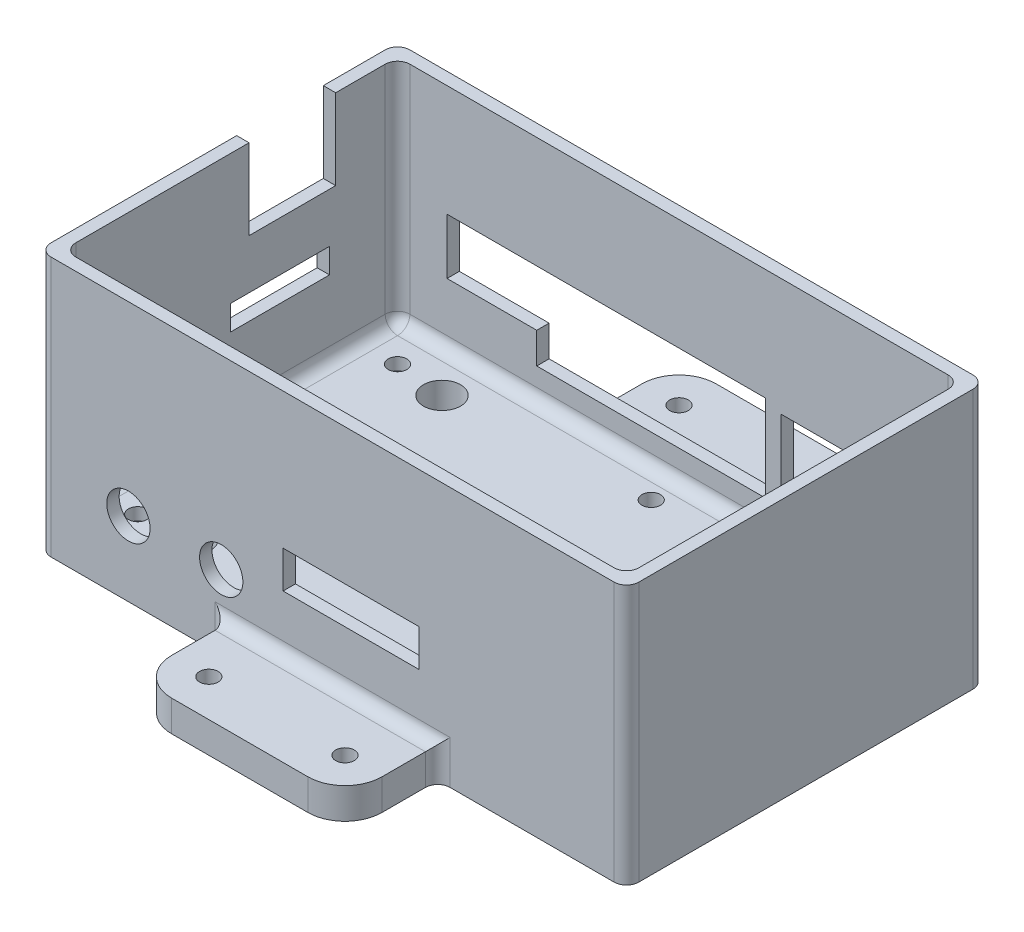
from build123d import *

# Parameters (mm, degrees)
SKETCH1_W                                          = 93
SKETCH1_H                                          = 58
BOSS_EXTRUDE1_DEPTH                                = 42
SKETCH2_W                                          = 91
SKETCH2_H                                          = 54
CUT_EXTRUDE1_DEPTH                                 = 19
CUT_EXTRUDE2_DEPTH                                 = 18
SKETCH4_W                                          = 58
SKETCH4_H                                          = 42
BOSS_EXTRUDE2_DEPTH                                = 2
SKETCH5_W                                          = 34
SKETCH5_H                                          = 5
BOSS_EXTRUDE3_DEPTH                                = 15
CUT_EXTRUDE3_REACH                                 = 97
SKETCH6_W                                          = 13.999999973
SKETCH6_H                                          = 12.999999419
CUT_EXTRUDE4_DEPTH                                 = 18
CUT_EXTRUDE5_REACH                                 = 97
SKETCH8_W                                          = 16
SKETCH8_H                                          = 4
SKETCH9_W                                          = 22.000000328
SKETCH9_H                                          = 6
CUT_EXTRUDE6_DEPTH                                 = 74
SKETCH10_W                                         = 34
SKETCH10_H                                         = 5
BOSS_EXTRUDE4_DEPTH                                = 15
F_3_0_3_DIAMETER_HOLE1_D                           = 3
F_3_0_3_DIAMETER_HOLE1_DEPTH                       = 5
F_6_0_6_DIAMETER_HOLE1_D                           = 6
F_6_0_6_DIAMETER_HOLE1_DEPTH                       = 5
F_7_0_7_DIAMETER_HOLE1_D                           = 7
F_7_0_7_DIAMETER_HOLE1_DEPTH                       = 2
F_8_0_8_DIAMETER_HOLE1_D                           = 8
F_8_0_8_DIAMETER_HOLE1_DEPTH                       = 2
CBORE_FOR_M2_5_HEX_HEAD_MACHINE_SCREW1_D           = 3
CBORE_FOR_M2_5_HEX_HEAD_MACHINE_SCREW1_DEPTH       = 42
CBORE_FOR_M2_5_HEX_HEAD_MACHINE_SCREW1_CBORE_D     = 6
CBORE_FOR_M2_5_HEX_HEAD_MACHINE_SCREW1_CBORE_DEPTH = 3
FILLET1_R                                          = 2
FILLET2_R                                          = 6


with BuildPart() as part:
    # Sketch1 → Boss-Extrude1 (new body)
    with BuildSketch(Plane.XZ):
        with Locations((-1, 0)):
            Rectangle(SKETCH1_W, SKETCH1_H)
    extrude(amount=-BOSS_EXTRUDE1_DEPTH)

    # Sketch2 → Cut-Extrude1 (cut)
    with BuildSketch(Plane(origin=(0, 42, 0), x_dir=(-1, 0, 0), z_dir=(0, 1, 0))):
        Rectangle(SKETCH2_W, SKETCH2_H)
    extrude(amount=-CUT_EXTRUDE1_DEPTH, mode=Mode.SUBTRACT)

    # Sketch3 → Cut-Extrude2 (cut)
    with BuildSketch(Plane(origin=(0, 23, 0), x_dir=(-1, 0, 0), z_dir=(0, 1, 0))):
        Polygon((-35.5, -29), (-16.5, -29), (-16.5, -27), (45.5, -27), (45.5, 27), (-45.5, 27), (-45.5, -27), (-35.5, -27), align=None)
    extrude(amount=-CUT_EXTRUDE2_DEPTH, mode=Mode.SUBTRACT)

    # Sketch4 → Boss-Extrude2 (add)
    with BuildSketch(Plane(origin=(45.5, 0, 0), x_dir=(0, 0, -1), z_dir=(1, 0, 0))):
        with Locations((0, 21)):
            Rectangle(SKETCH4_W, SKETCH4_H)
    extrude(amount=BOSS_EXTRUDE2_DEPTH)

    # Sketch5 → Boss-Extrude3 (add)
    with BuildSketch(Plane(origin=(0, 0, -29), x_dir=(-1, 0, 0), z_dir=(0, 0, -1))):
        with Locations((0, 2.5)):
            Rectangle(SKETCH5_W, SKETCH5_H)
    extrude(amount=BOSS_EXTRUDE3_DEPTH)

    # Sketch6 → Cut-Extrude3 (cut, up to next)
    with BuildSketch(Plane.ZY.offset(47.5), mode=Mode.PRIVATE) as cut_extrude3_sk1:
        with Locations((-10.000000013, 35.50000029)):
            Rectangle(SKETCH6_W, SKETCH6_H)
    cut_extrude3_tool1 = extrude(cut_extrude3_sk1.sketch, amount=-CUT_EXTRUDE3_REACH, mode=Mode.PRIVATE) & part.part
    add(cut_extrude3_tool1.solids().sort_by_distance((-47.5, 35.5, -10))[0], mode=Mode.SUBTRACT)

    # Sketch7 → Cut-Extrude4 (cut, through all)
    with BuildSketch(Plane.XY.offset(-27)):
        Polygon((14.000000071, 10), (14.000000071, 24), (-37.500000057, 24), (-37.500000057, 15), (-23.000000328, 15), (-23.000000328, 10), align=None)
    extrude(amount=-CUT_EXTRUDE4_DEPTH, mode=Mode.SUBTRACT)

    # Sketch8 → Cut-Extrude5 (cut, up to next)
    with BuildSketch(Plane.ZY.offset(47.5), mode=Mode.PRIVATE) as cut_extrude5_sk1:
        with Locations((-8, 19)):
            Rectangle(SKETCH8_W, SKETCH8_H)
    cut_extrude5_tool1 = extrude(cut_extrude5_sk1.sketch, amount=-CUT_EXTRUDE5_REACH, mode=Mode.PRIVATE) & part.part
    add(cut_extrude5_tool1.solids().sort_by_distance((-47.5, 19, -8))[0], mode=Mode.SUBTRACT)

    # Sketch9 → Cut-Extrude6 (cut, through all)
    with BuildSketch(Plane.XY.offset(29)):
        with Locations((2.999999836, 17)):
            Rectangle(SKETCH9_W, SKETCH9_H)
    extrude(amount=-CUT_EXTRUDE6_DEPTH, mode=Mode.SUBTRACT)

    # Sketch10 → Boss-Extrude4 (add)
    with BuildSketch(Plane.XY.offset(29)):
        with Locations((0, 2.5)):
            Rectangle(SKETCH10_W, SKETCH10_H)
    extrude(amount=BOSS_EXTRUDE4_DEPTH)

    # Ø3.0 (3) Diameter Hole1
    with Locations(Plane(origin=(0, 5, 0), x_dir=(1, 0, 0), z_dir=(0, 1, 0))):
        with Locations((11, -38), (-11, 38), (-11, -38), (11, 38), (0, 22.5), (0, -22.5), (-39.5, -12.925), (-39.5, -9.425)):
            Hole(F_3_0_3_DIAMETER_HOLE1_D / 2, depth=F_3_0_3_DIAMETER_HOLE1_DEPTH)

    # Ø6.0 (6) Diameter Hole1
    with Locations(Plane(origin=(0, 5, 0), x_dir=(1, 0, 0), z_dir=(0, 1, 0))):
        with Locations((31.540291459, -20.22658296), (-31.540291459, -20.22658296), (31.540291459, 20.22658296), (-31.540291459, 20.22658296)):
            Hole(F_6_0_6_DIAMETER_HOLE1_D / 2, depth=F_6_0_6_DIAMETER_HOLE1_DEPTH)

    # Ø7.0 (7) Diameter Hole1
    with Locations(Plane.XY.offset(29)):
        with Locations((-18.000000328, 12), (-33.000000328, 12)):
            Hole(F_7_0_7_DIAMETER_HOLE1_D / 2, depth=F_7_0_7_DIAMETER_HOLE1_DEPTH)

    # Ø8.0 (8) Diameter Hole1
    with Locations(Plane.ZY.offset(47.5)):
        with Locations((11.228, 17.5)):
            Hole(F_8_0_8_DIAMETER_HOLE1_D / 2, depth=F_8_0_8_DIAMETER_HOLE1_DEPTH)

    # CBORE for M2.5 Hex Head Machine Screw1
    with Locations(Plane(origin=(0, 0, 0), x_dir=(-1, 0, 0), z_dir=(0, -1, 0))):
        with Locations((-39.5, -21), (39.5, -21), (-39.5, 21), (39.5, 21)):
            CounterBoreHole(CBORE_FOR_M2_5_HEX_HEAD_MACHINE_SCREW1_D / 2, CBORE_FOR_M2_5_HEX_HEAD_MACHINE_SCREW1_CBORE_D / 2, CBORE_FOR_M2_5_HEX_HEAD_MACHINE_SCREW1_CBORE_DEPTH, depth=CBORE_FOR_M2_5_HEX_HEAD_MACHINE_SCREW1_DEPTH)

    # Fillet1
    fillet1_edges = [part.edges().sort_by_distance(p)[0] for p in [
        (40.5, 5, -27),
        (45.5, 23.5, -27),
        (-45.5, 23.5, -27),
        (-14.5, 5, -27),
        (45.5, 5, 0),
        (45.5, 23.5, 27),
        (-45.5, 5, 0),
        (0, 5, 27),
        (-45.5, 23.5, 27),
        (17, 2.5, 29),
        (0, 5, 29),
        (-17, 2.5, 29),
        (47.5, 21, 29),
        (-0.25, 5, -29),
        (-17, 2.5, -29),
        (-47.5, 21, 29),
        (17, 2.5, -29),
        (47.5, 21, -29),
        (-47.5, 21, -29),
    ]]
    fillet(fillet1_edges, radius=FILLET1_R)

    # Fillet2
    fillet2_edges = [part.edges().sort_by_distance(p)[0] for p in [
        (-17, 2.5, 44),
        (17, 2.5, 44),
        (-17, 2.5, -44),
        (17, 2.5, -44),
    ]]
    fillet(fillet2_edges, radius=FILLET2_R)


solid = part.part
